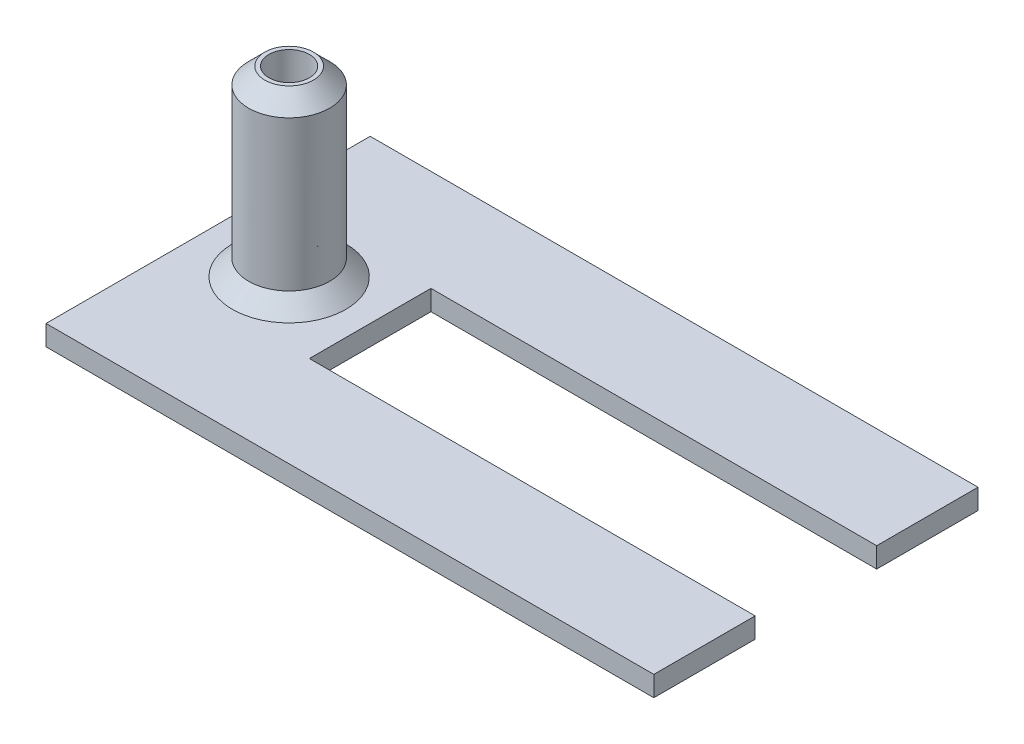
from build123d import *

# Parameters (mm, degrees)
BOSS_EXTRUDE1_DEPTH = 1
SKETCH4_R           = 2
SKETCH4_R_2         = 1
BOSS_EXTRUDE2_DEPTH = 10
CHAMFER1_SIZE       = 0.8


with BuildPart() as part:
    # Sketch3 → Boss-Extrude1 (new body)
    with BuildSketch(Plane(origin=(0, 0, 0), x_dir=(1, 0, 0), z_dir=(0, 1, 0))):
        Polygon((26, 8), (26, 3), (4, 3), (4, -3), (26, -3), (26, -8), (-4, -8), (-4, 8), align=None)
    extrude(amount=BOSS_EXTRUDE1_DEPTH)

    # Sketch4 → Boss-Extrude2 (add)
    with BuildSketch(Plane(origin=(0, 0, 0), x_dir=(1, 0, 0), z_dir=(0, 1, 0))):
        Circle(SKETCH4_R)
        Circle(SKETCH4_R_2, mode=Mode.SUBTRACT)
    extrude(amount=BOSS_EXTRUDE2_DEPTH)

    # Chamfer1
    chamfer1_edges = [part.edges().sort_by_distance(p)[0] for p in [
        (-2, 1, 0),
        (-2, 10, 0),
    ]]
    chamfer(chamfer1_edges, length=CHAMFER1_SIZE)


solid = part.part
